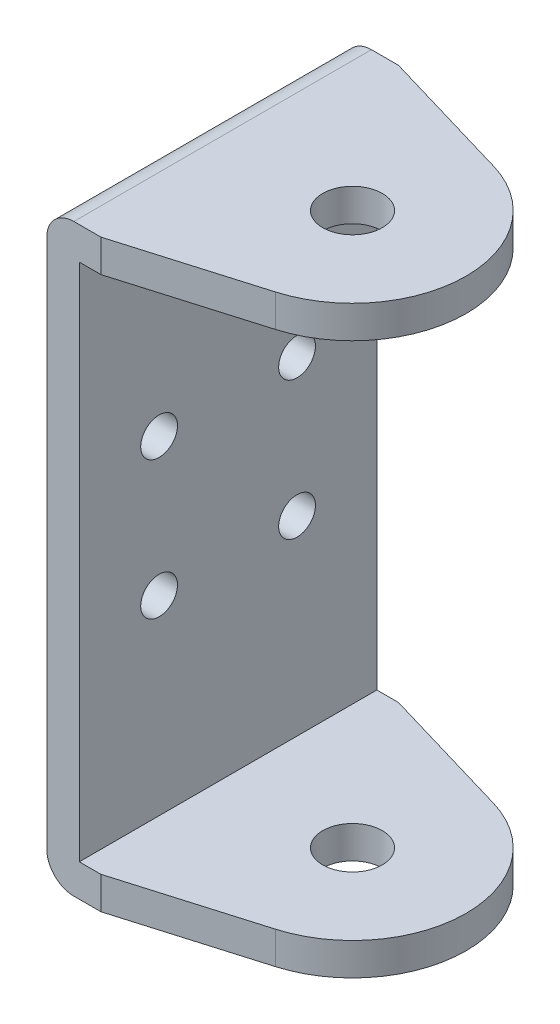
from build123d import *

# Parameters (mm, degrees)
EXTRUDE_1_DEPTH          = 27.5
HOLE_WIZARD_M10_1_D      = 8.5
SKETCH_6_R               = 3.4
CUT_EXTRUDE_1_DEPTH      = 10
SKETCH_9_R               = 5
CUT_EXTRUDE_2_DEPTH      = 136
CUT_EXTRUDE_3_DEPTH      = 1
CUT_EXTRUDE_3_DEPTH_BACK = 109
SKETCH_14_R              = 5.5
CUT_EXTRUDE_5_DEPTH      = 108


with BuildPart() as part:
    # 草圖1 → 填料-伸長1 (new body, symmetric)
    with BuildSketch(Plane.XY):
        with BuildLine():
            Line((0, -54), (-45, -54))
            ThreePointArc((-45, -54), (-48.535533906, -52.535533906), (-50, -49))
            Line((-50, -49), (-50, 49))
            ThreePointArc((-50, 49), (-48.535533906, 52.535533906), (-45, 54))
            Line((-45, 54), (0, 54))
            Line((0, 54), (0, 48))
            Line((0, 48), (-44, 48))
            Line((-44, 48), (-44, -48))
            Line((-44, -48), (0, -48))
            Line((0, -48), (0, -54))
        make_face()
    extrude(amount=EXTRUDE_1_DEPTH, both=True)

    # M10 螺紋孔1 (through all)
    with Locations(Plane(origin=(0, 54, 0), x_dir=(1, 0, 0), z_dir=(0, 1, 0))):
        with Locations((-21, 0)):
            Hole(HOLE_WIZARD_M10_1_D / 2)

    # 草圖6 → 除料-伸長1 (cut)
    with BuildSketch(Plane.ZY.offset(50)):
        with Locations((12.75, 12.75)):
            Circle(SKETCH_6_R)
        with Locations((-12.75, 12.75)):
            Circle(SKETCH_6_R)
        with Locations((-12.75, -12.75)):
            Circle(SKETCH_6_R)
        with Locations((12.75, -12.75)):
            Circle(SKETCH_6_R)
    extrude(amount=-CUT_EXTRUDE_1_DEPTH, mode=Mode.SUBTRACT)

    # 草圖9 → 除料-伸長2 (cut)
    with BuildSketch(Plane(origin=(0, 54, 0), x_dir=(1, 0, 0), z_dir=(0, 1, 0))):
        with Locations((-21, 0)):
            Circle(SKETCH_9_R)
    extrude(amount=-CUT_EXTRUDE_2_DEPTH, mode=Mode.SUBTRACT)

    # 草圖10 → 除料-伸長3 (cut, two sides)
    with BuildSketch(Plane(origin=(0, 54, 0), x_dir=(1, 0, 0), z_dir=(0, 1, 0))) as cut_extrude_3_sk:
        with BuildLine():
            Line((-180.04752128, 68.815685703), (-40, 27.5))
            Line((-40, 27.5), (-15.057931362, 20.141792877))
            ThreePointArc((-15.057931362, 20.141792877), (0, 0), (-15.057931362, -20.141792877))
            Line((-15.057931362, -20.141792877), (-40, -27.5))
            Line((-40, -27.5), (-180.04752128, -68.815685703))
            Line((-180.04752128, -68.815685703), (111.981888895, -68.815685703))
            Line((111.981888895, -68.815685703), (111.981888895, 68.815685703))
            Line((111.981888895, 68.815685703), (-180.04752128, 68.815685703))
        make_face()
    extrude(amount=CUT_EXTRUDE_3_DEPTH, mode=Mode.SUBTRACT)
    extrude(cut_extrude_3_sk.sketch, amount=-CUT_EXTRUDE_3_DEPTH_BACK, mode=Mode.SUBTRACT)

    # 草圖14 → 除料-伸長5 (cut)
    with BuildSketch(Plane(origin=(0, 54, 0), x_dir=(1, 0, 0), z_dir=(0, 1, 0))):
        with Locations((-21, 0)):
            Circle(SKETCH_14_R)
    extrude(amount=-CUT_EXTRUDE_5_DEPTH, mode=Mode.SUBTRACT)


solid = part.part
